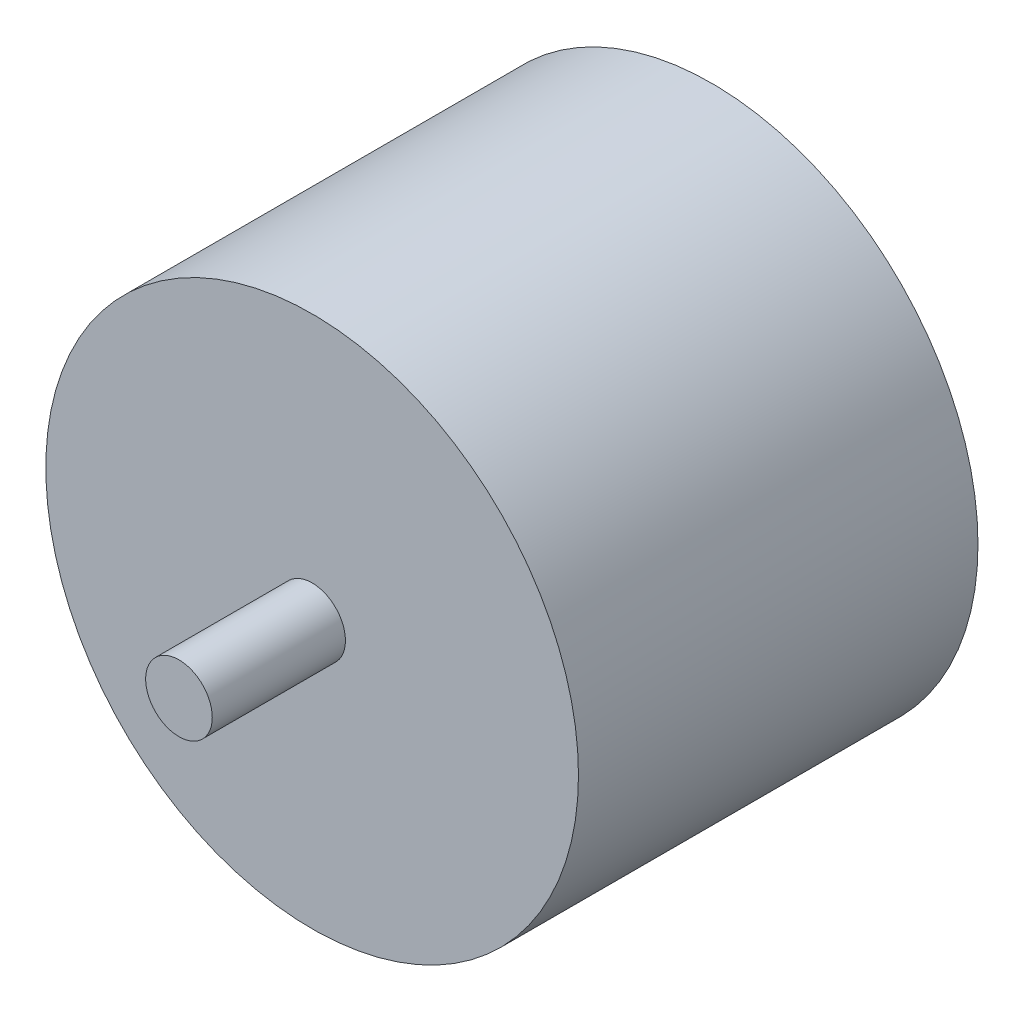
from build123d import *

# Parameters (mm, degrees)
SKETCH1_R           = 25.4
BOSS_EXTRUDE1_DEPTH = 19.05
SKETCH2_R           = 3.175
BOSS_EXTRUDE2_DEPTH = 12.7


with BuildPart() as part:
    # Sketch1 → Boss-Extrude1 (new body, symmetric)
    with BuildSketch(Plane.XY):
        Circle(SKETCH1_R)
    extrude(amount=BOSS_EXTRUDE1_DEPTH, both=True)

    # Sketch2 → Boss-Extrude2 (add)
    with BuildSketch(Plane.XY.offset(19.05)):
        Circle(SKETCH2_R)
    boss_extrude2 = extrude(amount=BOSS_EXTRUDE2_DEPTH)

    # Mirror1: Boss-Extrude2 across plane
    add(boss_extrude2.mirror(Plane.XY))


solid = part.part
